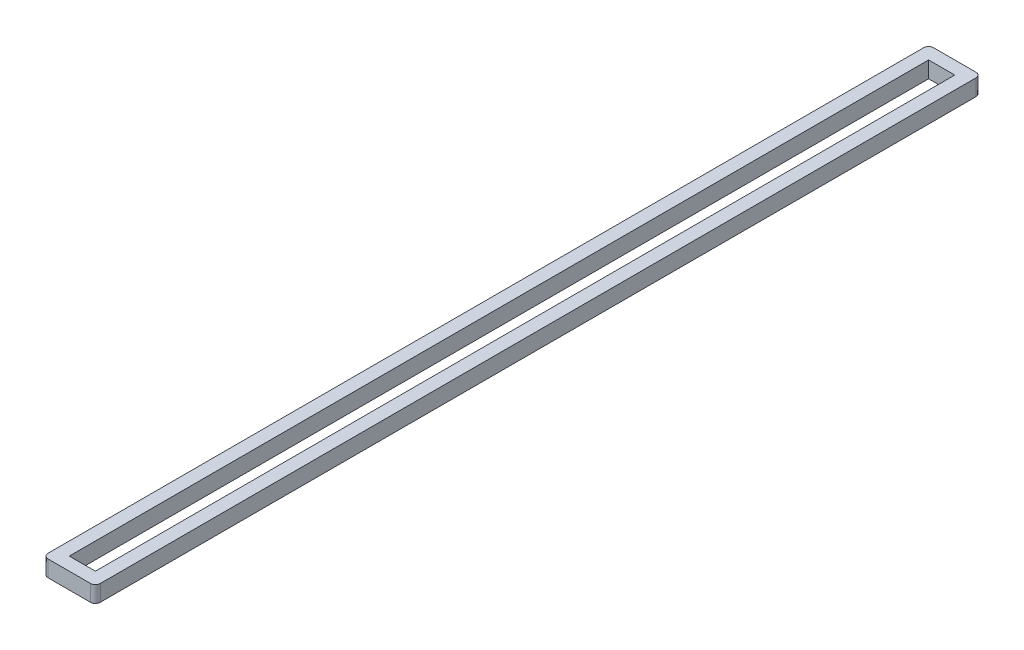
from build123d import *

# Parameters (mm, degrees)
SKETCH1_W           = 16
SKETCH1_H           = 271
SKETCH1_W_2         = 8
SKETCH1_H_2         = 263
BOSS_EXTRUDE1_DEPTH = 5
FILLET1_R           = 1.5


with BuildPart() as part:
    # Sketch1 → Boss-Extrude1 (new body)
    with BuildSketch(Plane(origin=(0, 0, 0), x_dir=(1, 0, 0), z_dir=(0, 1, 0))):
        Rectangle(SKETCH1_W, SKETCH1_H)
        Rectangle(SKETCH1_W_2, SKETCH1_H_2, mode=Mode.SUBTRACT)
    extrude(amount=BOSS_EXTRUDE1_DEPTH)

    # Fillet1
    fillet1_edges = [part.edges().sort_by_distance(p)[0] for p in [
        (8, 2.5, 135.5),
        (-8, 2.5, 135.5),
        (-8, 2.5, -135.5),
        (8, 2.5, -135.5),
    ]]
    fillet(fillet1_edges, radius=FILLET1_R)


solid = part.part
